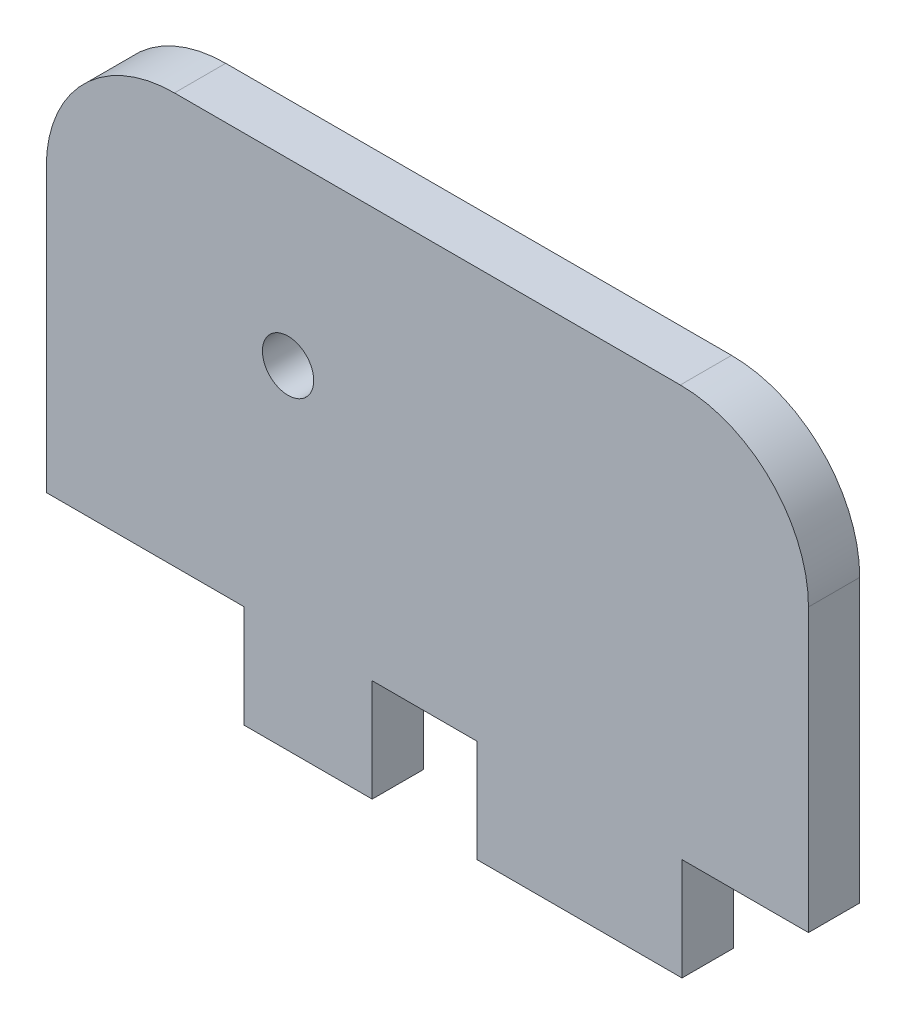
from build123d import *

# Parameters (mm, degrees)
SKETCH1_R           = 1
BOSS_EXTRUDE1_DEPTH = 2


with BuildPart() as part:
    # Sketch1 → Boss-Extrude1 (new body)
    with BuildSketch(Plane.XY):
        with BuildLine():
            Line((9.9326669, -1), (14.865841105, -1))
            Line((14.865841105, -1), (14.865841105, 10))
            ThreePointArc((14.865841105, 10), (13.401375011, 13.535533906), (9.865841105, 15))
            Line((9.865841105, 15), (-9.865841105, 15))
            ThreePointArc((-9.865841105, 15), (-13.401375011, 13.535533906), (-14.865841105, 10))
            Line((-14.865841105, 10), (-14.865841105, -1))
            Line((-14.865841105, -1), (-7.151873985, -1))
            Line((-7.151873985, -1), (-7.151873985, -5))
            Line((-7.151873985, -5), (-2.151873985, -5))
            Line((-2.151873985, -5), (-2.151873985, -1))
            Line((-2.151873985, -1), (1.9326669, -1))
            Line((1.9326669, -1), (1.9326669, -5))
            Line((1.9326669, -5), (9.9326669, -5))
            Line((9.9326669, -5), (9.9326669, -1))
        make_face()
        with Locations((-5.434158895, 8)):
            Circle(SKETCH1_R, mode=Mode.SUBTRACT)
    extrude(amount=BOSS_EXTRUDE1_DEPTH)


solid = part.part
